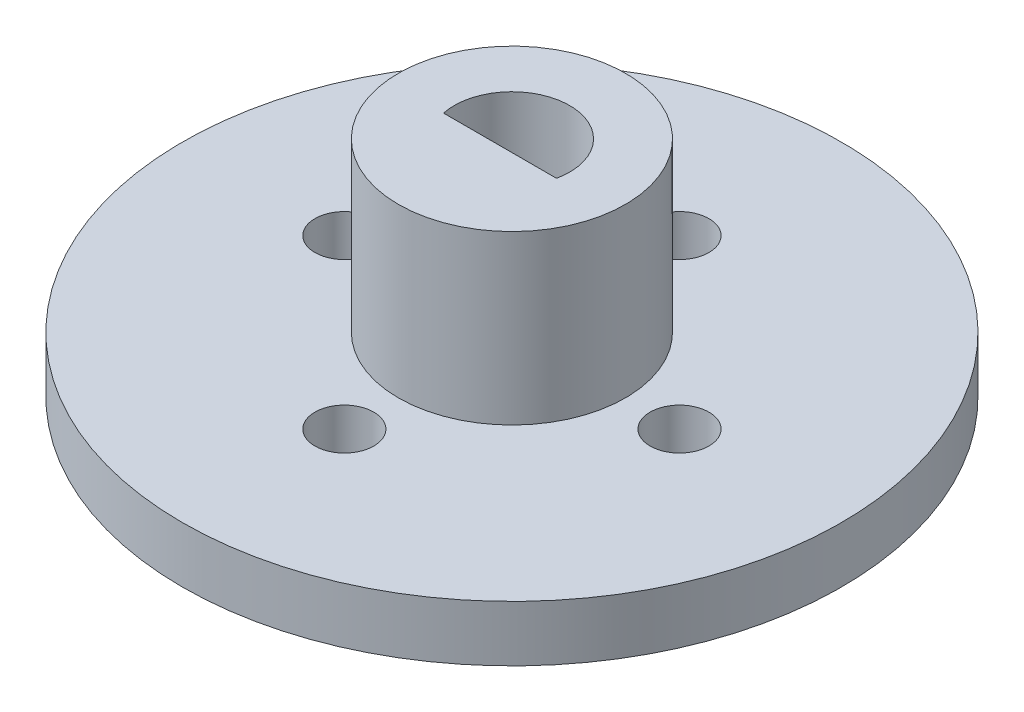
from build123d import *

# Parameters (mm, degrees)
SKETCH2_R               = 17.7
BOSS_EXTRUDE3_DEPTH     = 3
SKETCH3_R               = 3.1
CUT_EXTRUDE3_DEPTH      = 4
CUT_EXTRUDE3_DEPTH_BACK = 1
SKETCH5_R               = 6.1
BOSS_EXTRUDE4_DEPTH     = 9
SKETCH4_R               = 1.58
CUT_EXTRUDE4_DEPTH      = 13
CUT_EXTRUDE4_DEPTH_BACK = 1
SKETCH6_R               = 3.1
CUT_EXTRUDE5_DEPTH      = 10
SKETCH7_W               = 6.2
SKETCH7_H               = 2.46
BOSS_EXTRUDE5_DEPTH     = 12


with BuildPart() as part:
    # Sketch2 → Boss-Extrude3 (new body)
    with BuildSketch(Plane(origin=(0, 0, 0), x_dir=(-1, 0, 0), z_dir=(0, 1, 0))):
        Circle(SKETCH2_R)
    extrude(amount=BOSS_EXTRUDE3_DEPTH)

    # Sketch3 → Cut-Extrude3 (cut, two sides)
    with BuildSketch(Plane(origin=(0, 0, 0), x_dir=(1, 0, 0), z_dir=(0, 1, 0))) as cut_extrude3_sk:
        Circle(SKETCH3_R)
    extrude(amount=CUT_EXTRUDE3_DEPTH, mode=Mode.SUBTRACT)
    extrude(cut_extrude3_sk.sketch, amount=-CUT_EXTRUDE3_DEPTH_BACK, mode=Mode.SUBTRACT)

    # Sketch5 → Boss-Extrude4 (add)
    with BuildSketch(Plane(origin=(0, 3, 0), x_dir=(1, 0, 0), z_dir=(0, 1, 0))):
        Circle(SKETCH5_R)
    extrude(amount=BOSS_EXTRUDE4_DEPTH)

    # Sketch4 → Cut-Extrude4 (cut, two sides)
    with BuildSketch(Plane(origin=(0, 0, 0), x_dir=(1, 0, 0), z_dir=(0, 1, 0))) as cut_extrude4_sk:
        with Locations((-9, 0)):
            Circle(SKETCH4_R)
        with Locations((9, 0)):
            Circle(SKETCH4_R)
        with Locations((0, 9)):
            Circle(SKETCH4_R)
        with Locations((0, -9)):
            Circle(SKETCH4_R)
    extrude(amount=CUT_EXTRUDE4_DEPTH, mode=Mode.SUBTRACT)
    extrude(cut_extrude4_sk.sketch, amount=-CUT_EXTRUDE4_DEPTH_BACK, mode=Mode.SUBTRACT)

    # Sketch6 → Cut-Extrude5 (cut)
    with BuildSketch(Plane.XZ.offset(-3)):
        Circle(SKETCH6_R)
    extrude(amount=-CUT_EXTRUDE5_DEPTH, mode=Mode.SUBTRACT)

    # Sketch7 → Boss-Extrude5 (add)
    with BuildSketch(Plane.XZ):
        with Locations((0, 1.87)):
            Rectangle(SKETCH7_W, SKETCH7_H)
    extrude(amount=-BOSS_EXTRUDE5_DEPTH)


solid = part.part
